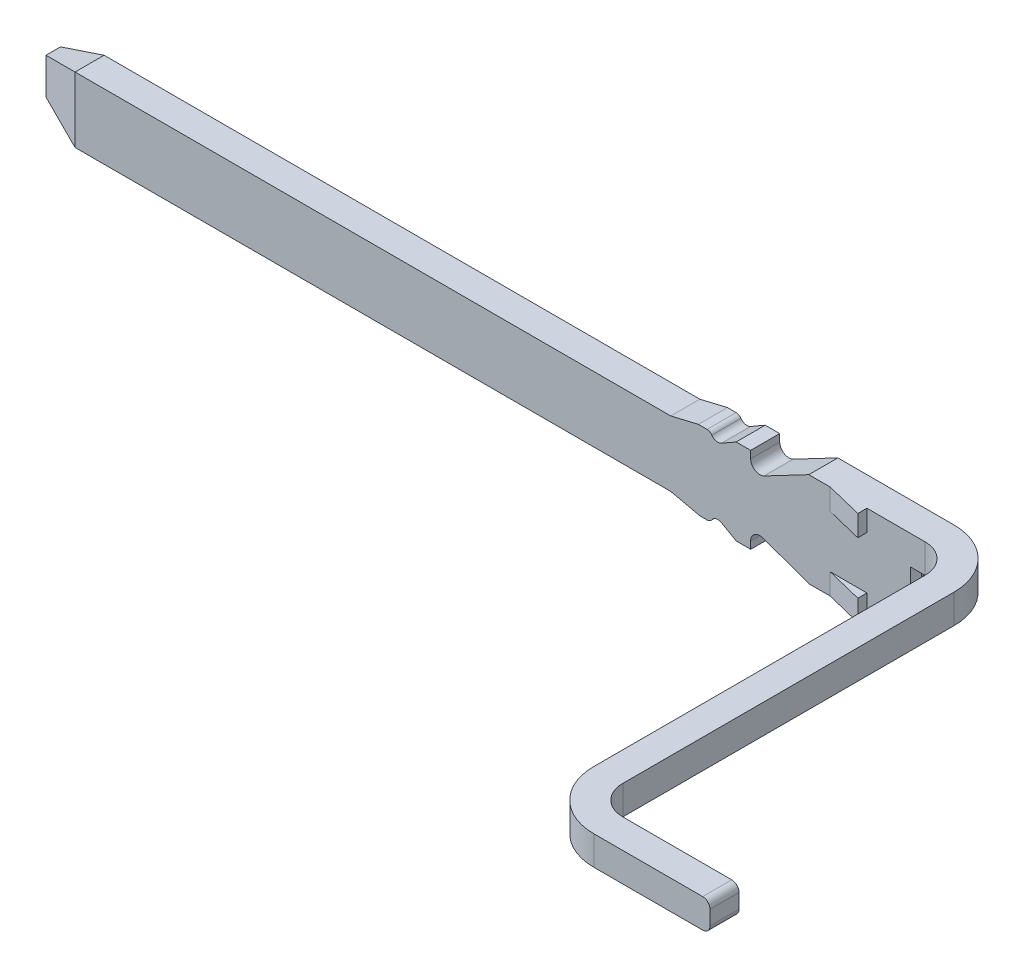
from build123d import *

# Parameters (mm, degrees)
RESSALTO_EXTRUS_O1_DEPTH = 0.2
RESSALTO_EXTRUS_O2_DEPTH = 0.2
CORTE_EXTRUS_O1_DEPTH    = 1
FILETE1_R                = 0.05
RESSALTO_EXTRUS_O3_DEPTH = 0.145
PADR_O_LINEAR1_COUNT     = 2
PADR_O_LINEAR1_PITCH     = 0.505
CORTE_EXTRUS_O2_DEPTH    = 0.3


with BuildPart() as part:
    # Esboço1 → Ressalto-extrusão1 (new body)
    with BuildSketch(Plane.XY):
        with BuildLine():
            Line((76.710328142, 206.616112347), (76.710328142, 206.416112347))
            Line((76.710328142, 206.416112347), (76.657349848, 206.416112347))
            Line((76.657349848, 206.416112347), (76.657349848, 206.116112347))
            Line((76.657349848, 206.116112347), (76.645328142, 206.116112347))
            Line((76.645328142, 206.116112347), (76.610328142, 206.116112347))
            Line((76.610328142, 206.116112347), (76.560328142, 206.116112347))
            ThreePointArc((76.560328142, 206.116112347), (76.524972803, 206.101467686), (76.510328142, 206.066112347))
            Line((76.510328142, 206.066112347), (76.510328142, 205.966112347))
            Line((76.510328142, 205.966112347), (76.110328142, 205.966112347))
            Line((76.110328142, 205.966112347), (76.081970009, 205.966112347))
            Line((76.081970009, 205.966112347), (75.910328142, 205.966112347))
            Line((75.910328142, 205.966112347), (75.595453106, 206.080717488))
            ThreePointArc((75.595453106, 206.080717488), (75.537376388, 206.073071543), (75.510328142, 206.021112347))
            Line((75.510328142, 206.021112347), (75.510328142, 205.971112347))
            Line((75.510328142, 205.971112347), (75.410328142, 205.971112347))
            Line((75.410328142, 205.971112347), (75.309933917, 206.02907498))
            ThreePointArc((75.309933917, 206.02907498), (75.273690046, 206.034493063), (75.243486264, 206.013739619))
            ThreePointArc((75.243486264, 206.013739619), (75.229104336, 206.000793024), (75.210328142, 205.996112347))
            Line((75.210328142, 205.996112347), (75.160328142, 205.996112347))
            Line((75.160328142, 205.996112347), (74.960328142, 206.041112347))
            Line((74.960328142, 206.041112347), (70.860328142, 206.041112347))
            Line((70.860328142, 206.041112347), (70.560328142, 206.141112347))
            Line((70.560328142, 206.141112347), (70.560328142, 206.391112347))
            Line((70.560328142, 206.391112347), (70.860328142, 206.491112347))
            Line((70.860328142, 206.491112347), (74.960328142, 206.491112347))
            Line((74.960328142, 206.491112347), (75.150344741, 206.536112347))
            Line((75.150344741, 206.536112347), (75.210328142, 206.536112347))
            ThreePointArc((75.210328142, 206.536112347), (75.229104336, 206.53143167), (75.243486264, 206.518485075))
            ThreePointArc((75.243486264, 206.518485075), (75.273690046, 206.497731631), (75.309933917, 206.503149714))
            Line((75.309933917, 206.503149714), (75.410328142, 206.561112347))
            Line((75.410328142, 206.561112347), (75.510328142, 206.561112347))
            Line((75.510328142, 206.561112347), (75.510328142, 206.511112347))
            ThreePointArc((75.510328142, 206.511112347), (75.540942979, 206.456830135), (75.60323487, 206.454946752))
            Line((75.60323487, 206.454946752), (75.910328142, 206.616112347))
            Line((75.910328142, 206.616112347), (76.081970009, 206.616112347))
            Line((76.081970009, 206.616112347), (76.110328142, 206.616112347))
            Line((76.110328142, 206.616112347), (76.710328142, 206.616112347))
        make_face()
    extrude(amount=RESSALTO_EXTRUS_O1_DEPTH)

    # Esboço2 → Ressalto-extrusão2 (add)
    with BuildSketch(Plane.XZ.offset(-206.416112347)):
        with BuildLine():
            Line((76.710328142, 0), (76.710328142, 0.2))
            ThreePointArc((76.710328142, 0.2), (76.851749499, 0.258578644), (76.910328142, 0.4))
            Line((76.910328142, 0.4), (76.910328142, 2.68))
            ThreePointArc((76.910328142, 2.68), (77.02748543, 2.962842712), (77.310328142, 3.08))
            Line((77.310328142, 3.08), (78.110328142, 3.08))
            Line((78.110328142, 3.08), (78.110328142, 2.88))
            Line((78.110328142, 2.88), (77.310328142, 2.88))
            ThreePointArc((77.310328142, 2.88), (77.168906786, 2.821421356), (77.110328142, 2.68))
            Line((77.110328142, 2.68), (77.110328142, 0.4))
            ThreePointArc((77.110328142, 0.4), (76.993170855, 0.117157288), (76.710328142, 0))
        make_face()
    extrude(amount=-RESSALTO_EXTRUS_O2_DEPTH)

    # Esboço3 → Corte-extrusão1 (cut)
    with BuildSketch(Plane(origin=(0, 206.491112347, 0), x_dir=(1, 0, 0), z_dir=(0, 1, 0))):
        Polygon((70.560328142, -0.1), (70.475949981, -0.1), (70.475949981, -0.288700335), (70.860328142, -0.288700335), (70.860328142, -0.2), align=None)
    extrude(amount=-CORTE_EXTRUS_O1_DEPTH, mode=Mode.SUBTRACT)

    # Filete1
    filete1_edges = [part.edges().sort_by_distance(p)[0] for p in [
        (78.110328142, 206.616112347, 2.98),
        (78.110328142, 206.416112347, 2.98),
    ]]
    fillet(filete1_edges, radius=FILETE1_R)

    # Esboço4 → Ressalto-extrusão3 (add)
    with BuildSketch(Plane(origin=(0, 206.616112347, 0), x_dir=(1, 0, 0), z_dir=(0, 1, 0))):
        Polygon((76.057628142, -0.2), (76.310328142, -0.2624), (76.310328142, -0.2), align=None)
    ressalto_extrus_o3 = extrude(amount=-RESSALTO_EXTRUS_O3_DEPTH)

    # Padrão linear1: Ressalto-extrusão3 ×2
    with Locations(*[(0, -i * PADR_O_LINEAR1_PITCH, 0) for i in range(1, PADR_O_LINEAR1_COUNT)]):
        add(ressalto_extrus_o3)

    # Esboço5 → Corte-extrusão2 (cut)
    with BuildSketch(Plane.XZ.offset(-206.116112347)):
        Polygon((76.657349848, 0.16), (76.645349848, 0.16), (76.608838995, 0.2), (76.608838995, 0.232444762), (76.679680574, 0.232444762), (76.679680574, 0.16), align=None)
        Polygon((76.608838995, 0), (76.645349848, 0.04), (76.679680574, 0.04), (76.679680574, -0.014078239), (76.608838995, -0.014078239), align=None)
    extrude(amount=-CORTE_EXTRUS_O2_DEPTH, mode=Mode.SUBTRACT)


solid = part.part
